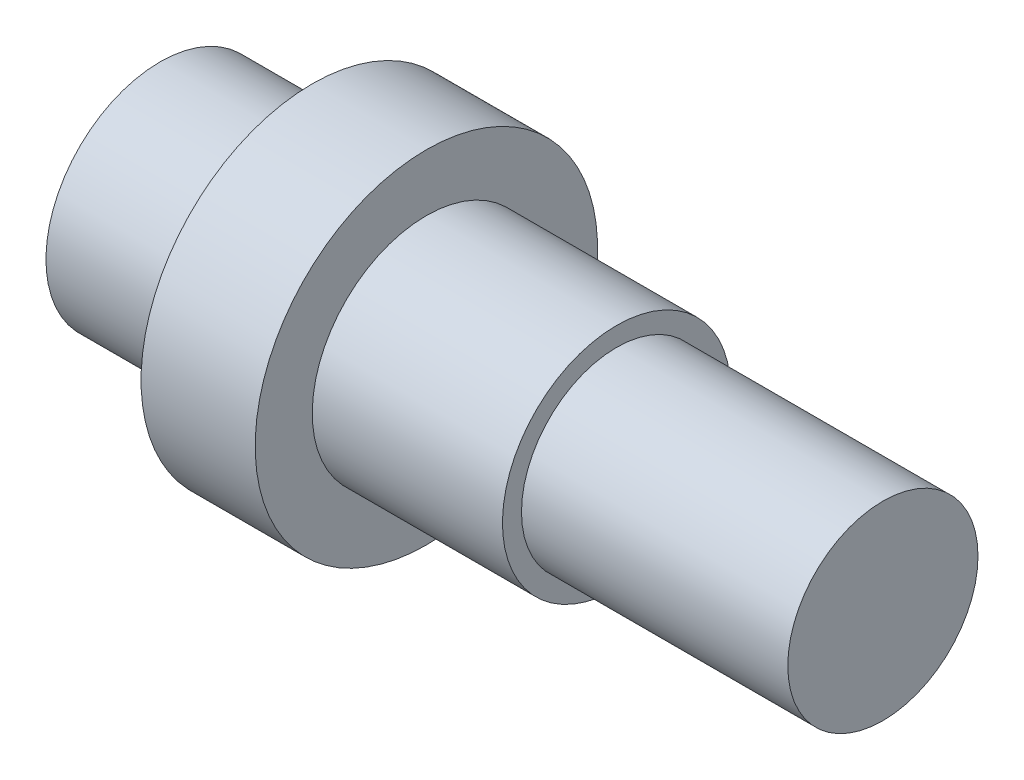
from build123d import *


with BuildPart() as part:
    # Skica1 → Rotovat1 (revolve)
    with BuildSketch(Plane.XY):
        Polygon((0, 0), (0, 15), (20, 15), (20, 22.5), (35, 22.5), (35, 15), (60, 15), (60, 12.5), (95, 12.5), (95, 0), align=None)
    revolve(axis=Axis((95, 0, 0), (-1, 0, 0)))


solid = part.part
